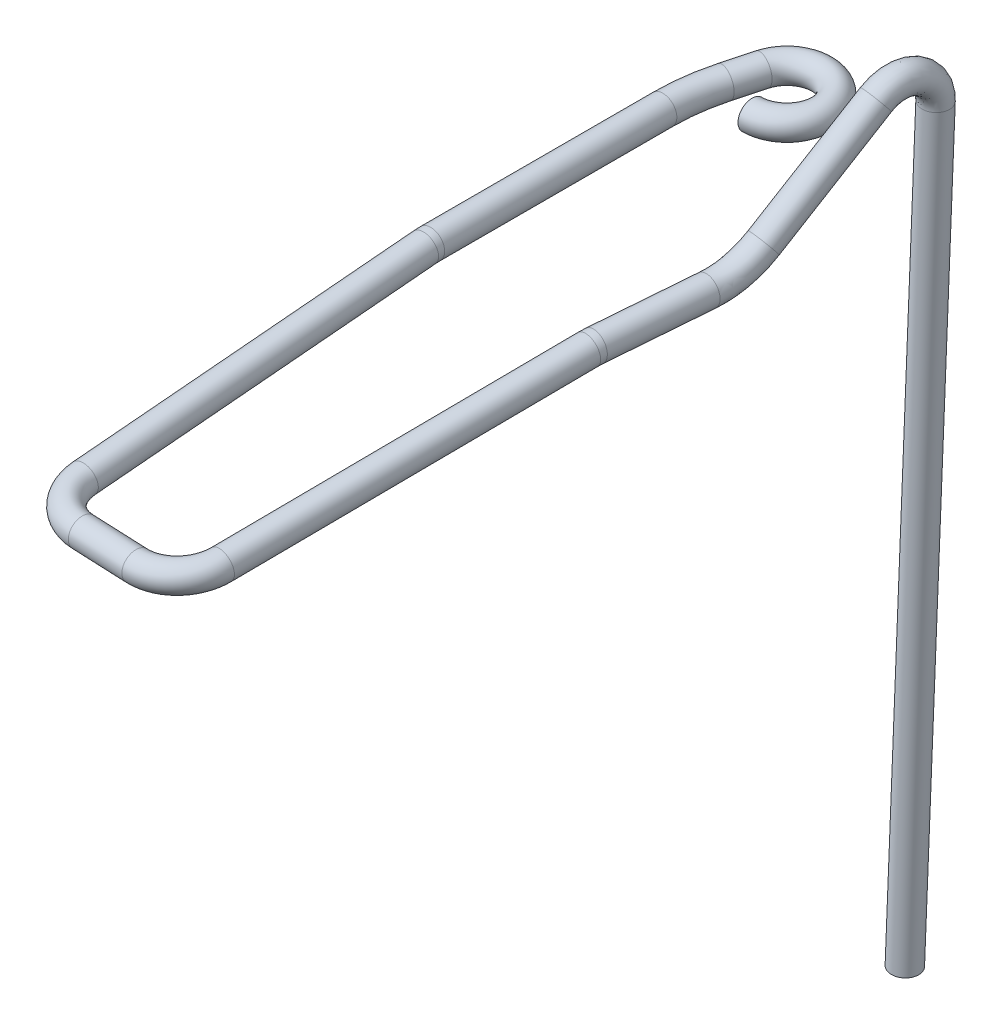
from build123d import *

# Parameters (mm, degrees)
SKETCH4_R  = 1
SKETCH12_R = 1
SKETCH15_R = 1
SKETCH17_R = 1
SKETCH18_R = 1


with BuildPart() as part:
    # Sweep1: sweep along a path in Sketch1
    with BuildLine(Plane(origin=(0, 0, 0), x_dir=(1, 0, 0), z_dir=(0, 1, 0))) as sweep1_path:
        Line((-3.5, -22), (-3.5, -5.377707027))
        ThreePointArc((-3.5, -5.377707027), (-3.371672921, -3.419814144), (-2.988887394, -1.495421351))
        Line((-2.988887394, -1.495421351), (-2.414814566, 0.647047613))
        ThreePointArc((-2.414814566, 0.647047613), (1.983383351, 1.521903573), (0, -2.5))
    # Sketch4 → Sweep1 (sweep)
    with BuildSketch(Plane(origin=(0, 0, 0), x_dir=(0, 0, -1), z_dir=(1, 0, 0))):
        with Locations((-2.5, 0)):
            Circle(SKETCH4_R)
    sweep(path=sweep1_path.line)

    # Sweep3: sweep along a path in Sketch13
    with BuildLine(Plane(origin=(-3.5, 0, 0), x_dir=(0, 0, -1), z_dir=(1, 0, 0))) as sweep3_path:
        Line((-46.800382717, -2.150653151), (-22.435778714, -0.01902651))
        ThreePointArc((-22.435778714, -0.01902651), (-22.218096937, -0.004758892), (-22, 0))
    # Sketch12 → Sweep3 (sweep)
    with BuildSketch(Plane.XY.offset(22)):
        with Locations((-3.5, 0)):
            Circle(SKETCH12_R)
    sweep(path=sweep3_path.line)

    # Sweep4: sweep along a path in Sketch14
    with BuildLine(Plane(origin=(-3.5, -2.150653151, 46.800382717), x_dir=(1, 0, 0), z_dir=(0, -0.996194698, -0.087155743))) as sweep4_path:
        ThreePointArc((0, 0), (0.870924887, 2.162875704), (2.997651292, 3.118687539))
        Line((2.997651292, 3.118687539), (6.994459827, 3.276935222))
        ThreePointArc((6.994459827, 3.276935222), (9.190720622, 2.492412633), (10.231107241, 0.405157771))
    # Sketch15 → Sweep4 (sweep)
    with BuildSketch(Plane(origin=(0, -4.079737213, 46.631609731), x_dir=(1, 0, 0), z_dir=(0, -0.087155743, 0.996194698))):
        with Locations((-3.5, 1.93645285)):
            Circle(SKETCH15_R)
    sweep(path=sweep4_path.line)

    # Sweep5: sweep along a path in Sketch16
    with BuildLine(Plane(origin=(7.603209026, -1.23489811, 36.333254701), x_dir=(0.079350865, -0.001896768, -0.996844944), z_dir=(0.996821663, -0.006943295, 0.079362223))) as sweep5_path:
        Line((-10.903844313, -0.971774103), (13.4469751, 1.240773237))
        ThreePointArc((13.4469751, 1.240773237), (13.668227032, 1.255937979), (13.889933785, 1.261276763))
        Line((13.889933785, 1.261276763), (21.389920293, 1.275502866))
    # Sketch17 → Sweep5 (sweep)
    with BuildSketch(Plane(origin=(-3.706717657, -4.042345066, 46.204215535), x_dir=(-0.996802687, 0.013089991, -0.078822935), z_dir=(0.079665374, 0.086878732, -0.993028456))):
        with Locations((-10.458957754, 2.001025934)):
            Circle(SKETCH17_R)
    sweep(path=sweep5_path.line)

    # Sweep2: sweep along a path in Sketch3
    with BuildLine(Plane(origin=(9.16491107, -2.974077254, 15.189541911), x_dir=(0.075754294, -0.077452472, -0.994113878), z_dir=(-0.995896916, 0.043619387, -0.079288599))) as sweep2_path:
        Line((18.791142113, 45.703836776), (14.527197797, -9.130630294))
        ThreePointArc((14.527197797, -9.130630294), (12.951106975, -11.262806607), (10.344231445, -10.778618545))
        Line((10.344231445, -10.778618545), (3.551994264, -4.544397336))
        ThreePointArc((3.551994264, -4.544397336), (1.886999302, -3.462230606), (-0.040025557, -2.982784838))
    # Sketch18 → Sweep2 (sweep)
    with BuildSketch(Plane(origin=(-1.128626929, 0.024536721, 14.17815798), x_dir=(-0.996843953, -0.002464328, -0.079347717), z_dir=(0.079352077, -0.00172514, -0.996845159))):
        with Locations((-10.471095378, -0.050341166)):
            Circle(SKETCH18_R)
    sweep(path=sweep2_path.line)


solid = part.part
